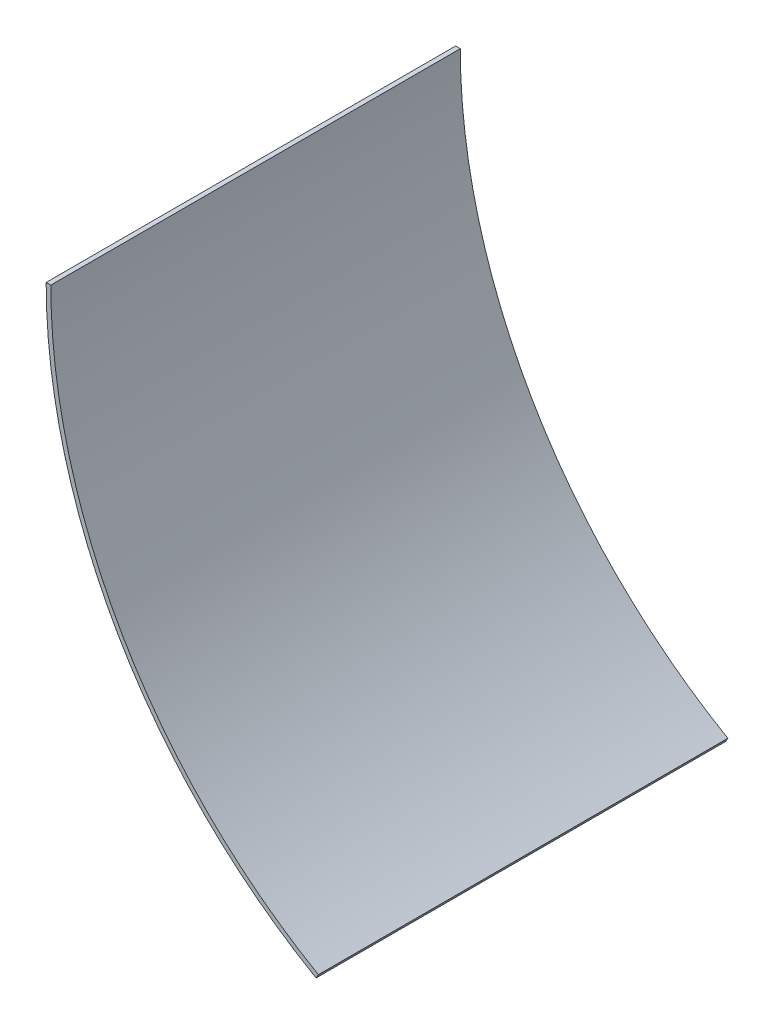
from build123d import *

# Parameters (mm, degrees)
BOSS_EXTRUDE1_DEPTH = 139.7


with BuildPart() as part:
    # Sketch1 → Boss-Extrude1 (new body)
    with BuildSketch(Plane.XY):
        with BuildLine():
            Line((-184.15, 0), (-182.5625, 0))
            ThreePointArc((-182.5625, 0), (-158.103762778, -91.28125), (-91.28125, -158.103762778))
            Line((-91.28125, -158.103762778), (-92.075, -159.478578107))
            ThreePointArc((-92.075, -159.478578107), (-159.478578107, -92.075), (-184.15, 0))
        make_face()
    extrude(amount=BOSS_EXTRUDE1_DEPTH)


solid = part.part
